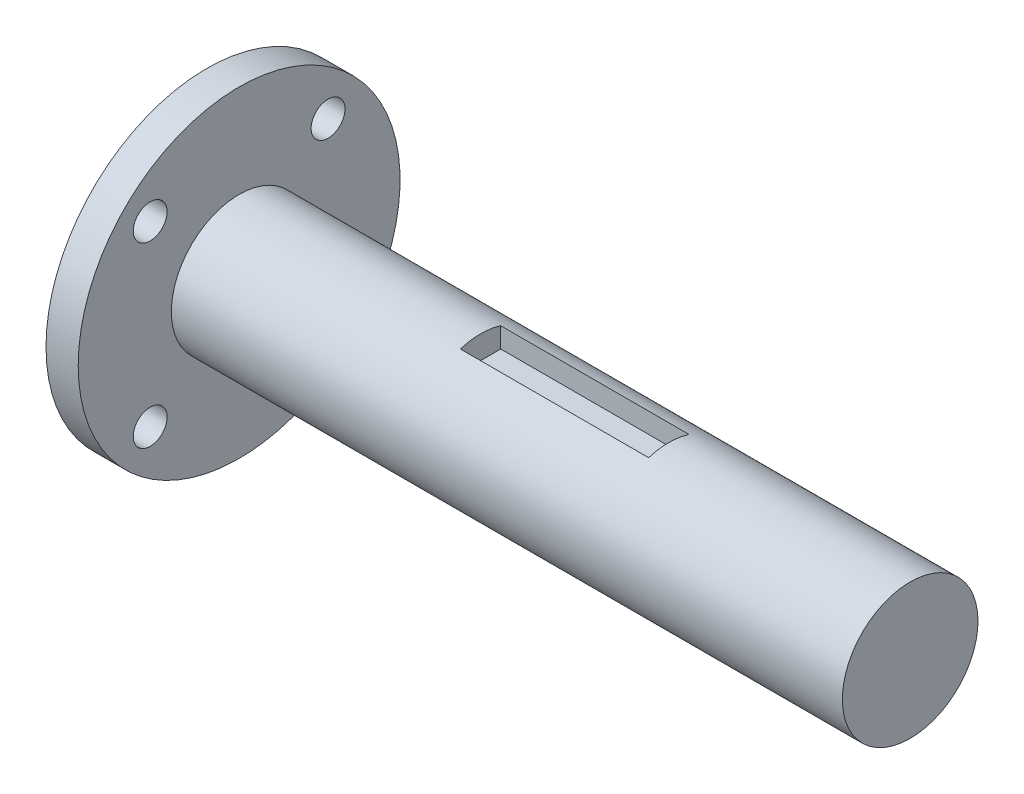
from build123d import *

# Parameters (mm, degrees)
SKETCH1_R           = 8.005
BOSS_EXTRUDE1_DEPTH = 28.5
SKETCH4_R           = 19
SKETCH4_R_2         = 2
BOSS_EXTRUDE3_DEPTH = 3.8
BOSS_EXTRUDE5_DEPTH = 22.225
SKETCH7_R           = 8.005
BOSS_EXTRUDE6_DEPTH = 28.5


with BuildPart() as part:
    # Sketch1 → Boss-Extrude1 (new body)
    with BuildSketch(Plane(origin=(0, 0, 0), x_dir=(0, 0, -1), z_dir=(1, 0, 0))):
        Circle(SKETCH1_R)
    extrude(amount=BOSS_EXTRUDE1_DEPTH)

    # Sketch4 → Boss-Extrude3 (add)
    with BuildSketch(Plane.ZY):
        Circle(SKETCH4_R)
        with Locations((-10.5, 10.5)):
            Circle(SKETCH4_R_2, mode=Mode.SUBTRACT)
        with Locations((10.5, 10.5)):
            Circle(SKETCH4_R_2, mode=Mode.SUBTRACT)
        with Locations((10.5, -10.5)):
            Circle(SKETCH4_R_2, mode=Mode.SUBTRACT)
        with Locations((-10.5, -10.5)):
            Circle(SKETCH4_R_2, mode=Mode.SUBTRACT)
    extrude(amount=BOSS_EXTRUDE3_DEPTH)

    # Sketch6 → Boss-Extrude5 (add)
    with BuildSketch(Plane(origin=(28.5, 0, 0), x_dir=(0, 0, -1), z_dir=(1, 0, 0))):
        with BuildLine():
            Line((-2.3815, 5.259544), (2.3815, 5.259544))
            Line((2.3815, 5.259544), (2.3815, 7.642544))
            ThreePointArc((2.3815, 7.642544), (0, -8.005), (-2.3815, 7.642544))
            Line((-2.3815, 7.642544), (-2.3815, 5.259544))
        make_face()
    extrude(amount=BOSS_EXTRUDE5_DEPTH)

    # Sketch7 → Boss-Extrude6 (add)
    with BuildSketch(Plane(origin=(50.725, 0, 0), x_dir=(0, 0, -1), z_dir=(1, 0, 0))):
        Circle(SKETCH7_R)
    extrude(amount=BOSS_EXTRUDE6_DEPTH)


solid = part.part
